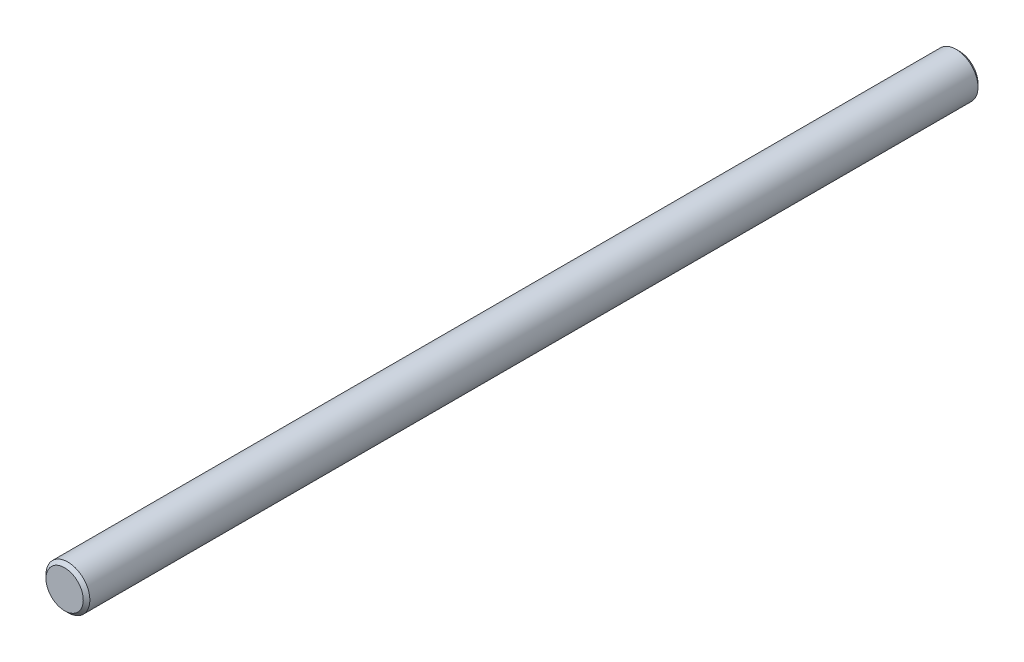
from build123d import *

# Parameters (mm, degrees)
SKETCH2_R                = 3.96875
BOSS_EXTRUDE1_DEPTH      = 80.9244
BOSS_EXTRUDE1_DEPTH_BACK = 80.9244
CHAMFER1_SIZE            = 0.5953125


with BuildPart() as part:
    # Sketch2 → Boss-Extrude1 (new body, two sides)
    with BuildSketch(Plane.XY) as boss_extrude1_sk:
        Circle(SKETCH2_R)
    extrude(amount=BOSS_EXTRUDE1_DEPTH)
    extrude(boss_extrude1_sk.sketch, amount=-BOSS_EXTRUDE1_DEPTH_BACK)

    # Chamfer1
    chamfer1_edges = [part.edges().sort_by_distance(p)[0] for p in [
        (-3.96875, 0, -80.9244),
        (-3.96875, 0, 80.9244),
    ]]
    chamfer(chamfer1_edges, length=CHAMFER1_SIZE)


solid = part.part
